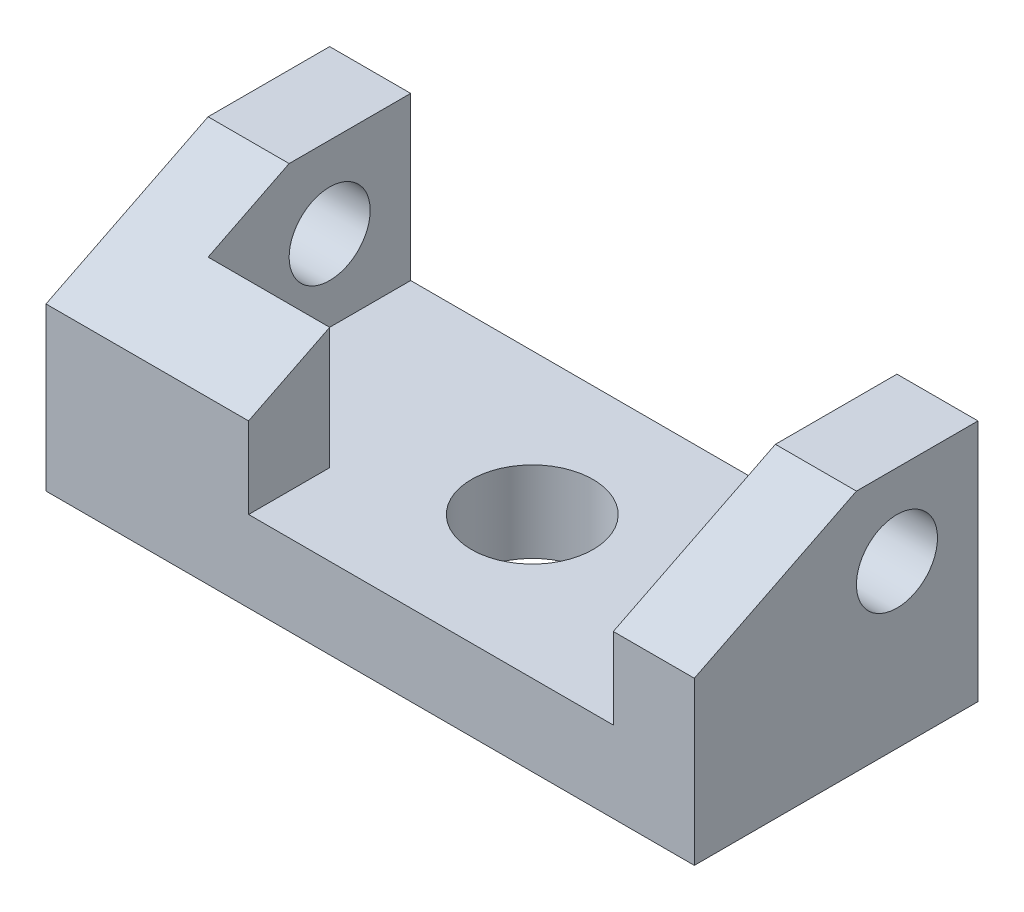
from build123d import *

# Parameters (mm, degrees)
SKETCH1_W           = 80
SKETCH1_H           = 35
BOSS_EXTRUDE1_DEPTH = 30
CUT_EXTRUDE1_DEPTH  = 20
CUT_EXTRUDE2_DEPTH  = 81
SKETCH4_R           = 5
CUT_EXTRUDE4_DEPTH  = 81
SKETCH5_R           = 7.5
CUT_EXTRUDE5_DEPTH  = 11


with BuildPart() as part:
    # Sketch1 → Boss-Extrude1 (new body)
    with BuildSketch(Plane(origin=(0, 0, 0), x_dir=(1, 0, 0), z_dir=(0, 1, 0))):
        with Locations((40, 17.5)):
            Rectangle(SKETCH1_W, SKETCH1_H)
    extrude(amount=BOSS_EXTRUDE1_DEPTH)

    # Sketch2 → Cut-Extrude1 (cut)
    with BuildSketch(Plane(origin=(0, 30, 0), x_dir=(1, 0, 0), z_dir=(0, 1, 0))):
        Polygon((10, 35), (10, 10.002355001), (25, 10.002355001), (25, 0), (70, 0), (70, 35), align=None)
    extrude(amount=-CUT_EXTRUDE1_DEPTH, mode=Mode.SUBTRACT)

    # Sketch3 → Cut-Extrude2 (cut, through all)
    with BuildSketch(Plane.ZY):
        Polygon((0, 30), (0, 20), (-20, 30), align=None)
    extrude(amount=-CUT_EXTRUDE2_DEPTH, mode=Mode.SUBTRACT)

    # Sketch4 → Cut-Extrude4 (cut, through all)
    with BuildSketch(Plane(origin=(80, 0, 0), x_dir=(0, 0, -1), z_dir=(1, 0, 0))):
        with Locations((25, 20)):
            Circle(SKETCH4_R)
    extrude(amount=-CUT_EXTRUDE4_DEPTH, mode=Mode.SUBTRACT)

    # Sketch5 → Cut-Extrude5 (cut, through all)
    with BuildSketch(Plane(origin=(0, 10, 0), x_dir=(1, 0, 0), z_dir=(0, 1, 0))):
        with Locations((42.5, 17.5)):
            Circle(SKETCH5_R)
    extrude(amount=-CUT_EXTRUDE5_DEPTH, mode=Mode.SUBTRACT)


solid = part.part
